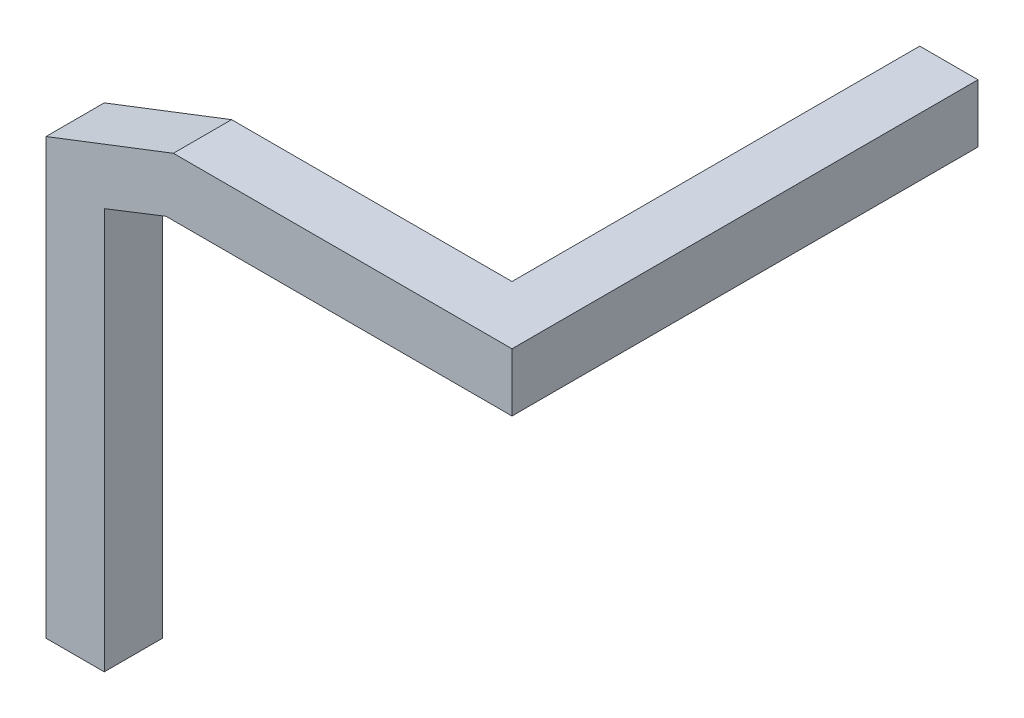
from build123d import *

# Parameters (mm, degrees)
SKETCH1_W           = 100
SKETCH1_H           = 100
BOSS_EXTRUDE1_DEPTH = 800
SKETCH2_W           = 100
SKETCH2_H           = 100
BOSS_EXTRUDE2_DEPTH = 700
CUT_EXTRUDE1_DEPTH  = 801
BOSS_EXTRUDE3_DEPTH = 100
SKETCH5_R           = 25
BOSS_EXTRUDE4_DEPTH = 25


with BuildPart() as part:
    # Sketch1 → Boss-Extrude1 (new body)
    with BuildSketch(Plane.XY):
        with Locations((50, 50)):
            Rectangle(SKETCH1_W, SKETCH1_H)
    extrude(amount=BOSS_EXTRUDE1_DEPTH)

    # Sketch2 → Boss-Extrude2 (add)
    with BuildSketch(Plane(origin=(0, 0, 0), x_dir=(0, 0, -1), z_dir=(1, 0, 0))):
        with Locations((-750, 50)):
            Rectangle(SKETCH2_W, SKETCH2_H)
    extrude(amount=-BOSS_EXTRUDE2_DEPTH)

    # Sketch3 → Cut-Extrude1 (cut, through all)
    with BuildSketch(Plane.XY):
        Polygon((-481.374152596, 100), (-700, 15.631226575), (-700, 100), align=None)
    extrude(amount=CUT_EXTRUDE1_DEPTH, mode=Mode.SUBTRACT)

    # Sketch4 → Boss-Extrude3 (add)
    with BuildSketch(Plane.XY.offset(800)):
        Polygon((-493.990986432, 0), (-600, -41.564522078), (-600, -730.356100977), (-700, -730.356100977), (-700, 0), align=None)
    extrude(amount=-BOSS_EXTRUDE3_DEPTH)

    # Sketch5 → Boss-Extrude4 (add)
    with BuildSketch(Plane(origin=(0, -730.356100977, 0), x_dir=(-1, 0, 0), z_dir=(0, -1, 0))):
        with Locations((650, -750)):
            Circle(SKETCH5_R)
    extrude(amount=BOSS_EXTRUDE4_DEPTH)


solid = part.part
